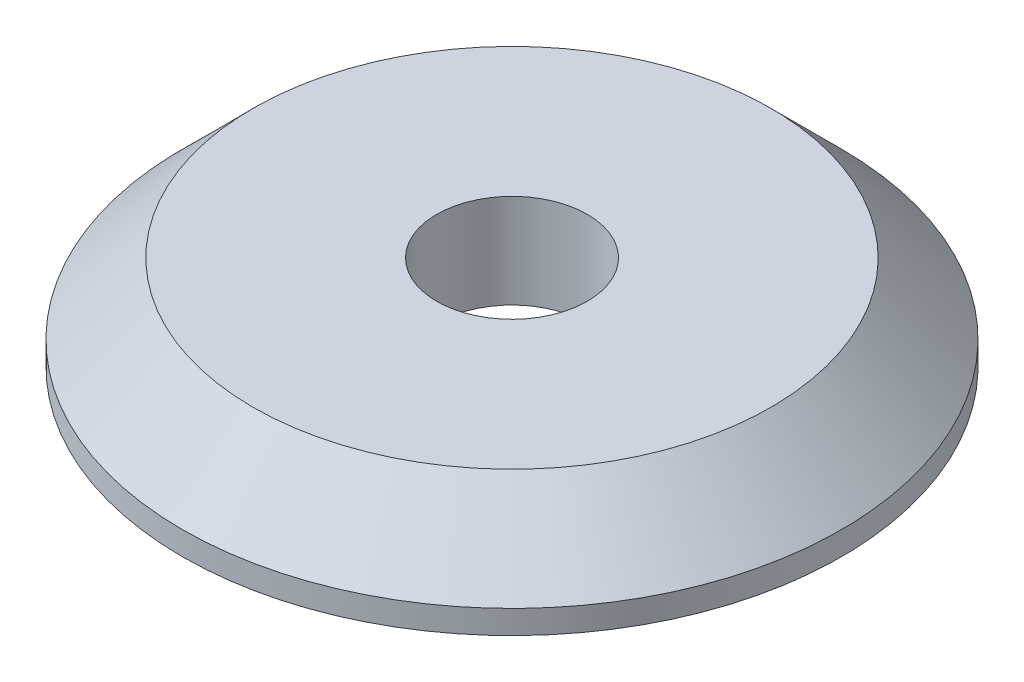
from build123d import *

# Parameters (mm, degrees)
SKETCH_1_R          = 7
EXTRUDE_1_DEPTH     = 2
CHAMFER_1_SIZE      = 1.5
SKETCH_2_R          = 1.6
CUT_EXTRUDE_1_DEPTH = 3


with BuildPart() as part:
    # Эскиз1 → Бобышка-Вытянуть1 (new body)
    with BuildSketch(Plane(origin=(0, 0, 0), x_dir=(1, 0, 0), z_dir=(0, 1, 0))):
        Circle(SKETCH_1_R)
    extrude(amount=EXTRUDE_1_DEPTH)

    # Фаска1
    chamfer_1_edges = [part.edges().sort_by_distance(p)[0] for p in [
        (-7, 2, 0),
    ]]
    chamfer(chamfer_1_edges, length=CHAMFER_1_SIZE)

    # Эскиз2 → Вырез-Вытянуть1 (cut, through all)
    with BuildSketch(Plane.XZ):
        Circle(SKETCH_2_R)
    extrude(amount=-CUT_EXTRUDE_1_DEPTH, mode=Mode.SUBTRACT)


solid = part.part
